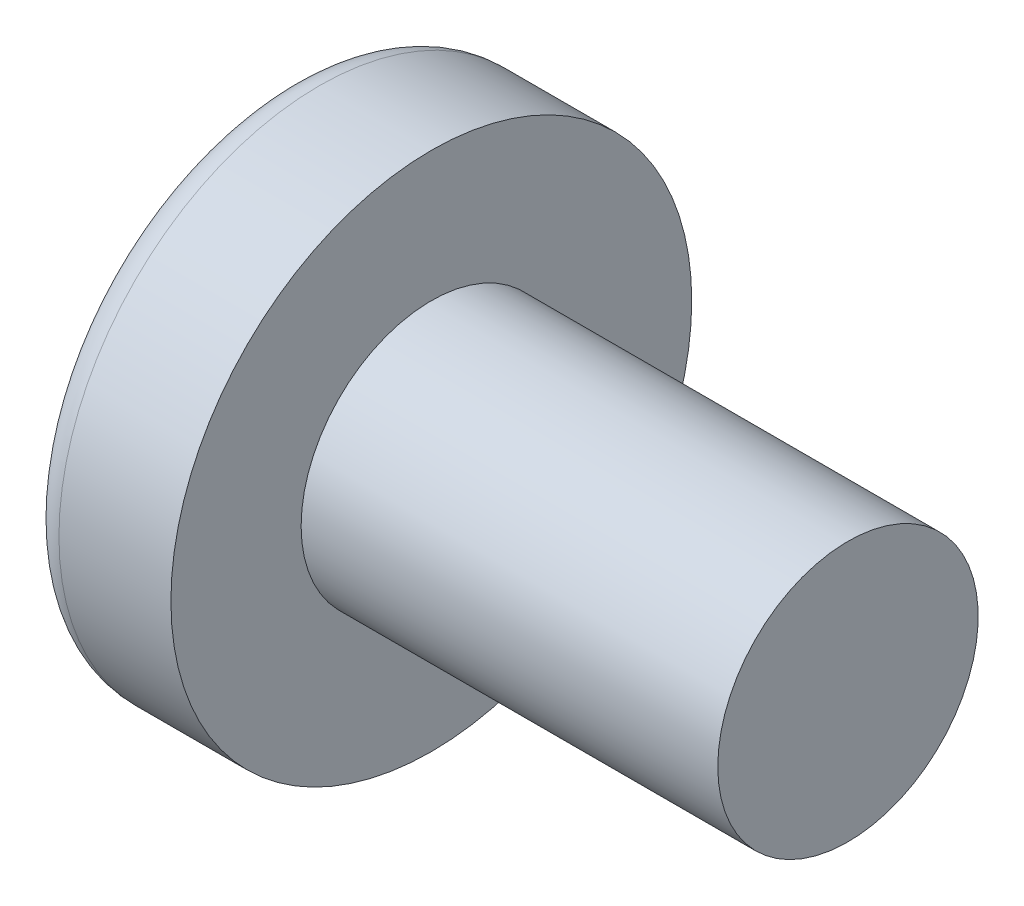
from build123d import *

# Parameters (mm, degrees)
SKETCH3_W         = 0.7
SKETCH3_H         = 2.68
SKETCH4_W         = 0.35
SKETCH4_H         = 0.35
CIRPATTERN1_COUNT = 2
CIRPATTERN1_ANGLE = 90


with BuildPart() as part:
    # BodySke → Base-Revolve (revolve)
    with BuildSketch(Plane.XY):
        with BuildLine():
            Line((2.1, 1.25), (2.1, 2.5))
            Line((2.1, 2.5), (1.025105044, 2.5))
            ThreePointArc((1.025105044, 2.5), (0.890037493, 2.467874517), (0.783897345, 2.378378378))
            ThreePointArc((0.783897345, 2.378378378), (0.201025755, 1.252116085), (0, 0))
            Line((0, 0), (6.1, 0))
            Line((6.1, 0), (6.1, 1.25))
            Line((6.1, 1.25), (2.1, 1.25))
        make_face()
    revolve(axis=Axis((-25.4, 0, 0), (1, 0, 0)))

    # Sketch3 → Cut-Loft1 section 0
    with BuildSketch(Plane(origin=(0, 0, 0), x_dir=(0, 0, -1), z_dir=(1, 0, 0))):
        Rectangle(SKETCH3_W, SKETCH3_H)
    # Sketch4 → Cut-Loft1 section 1
    with BuildSketch(Plane(origin=(1.53, 0, 0), x_dir=(0, 0, -1), z_dir=(1, 0, 0))):
        Rectangle(SKETCH4_W, SKETCH4_H)
    cut_loft1 = loft(mode=Mode.SUBTRACT)

    # CirPattern1: Cut-Loft1 ×2 about axis
    cirpattern1_axis = Axis((0, 0, 0), (1, 0, 0))
    for i in range(1, CIRPATTERN1_COUNT):
        add(cut_loft1.rotate(cirpattern1_axis, i * CIRPATTERN1_ANGLE / (CIRPATTERN1_COUNT - 1)), mode=Mode.SUBTRACT)


solid = part.part
